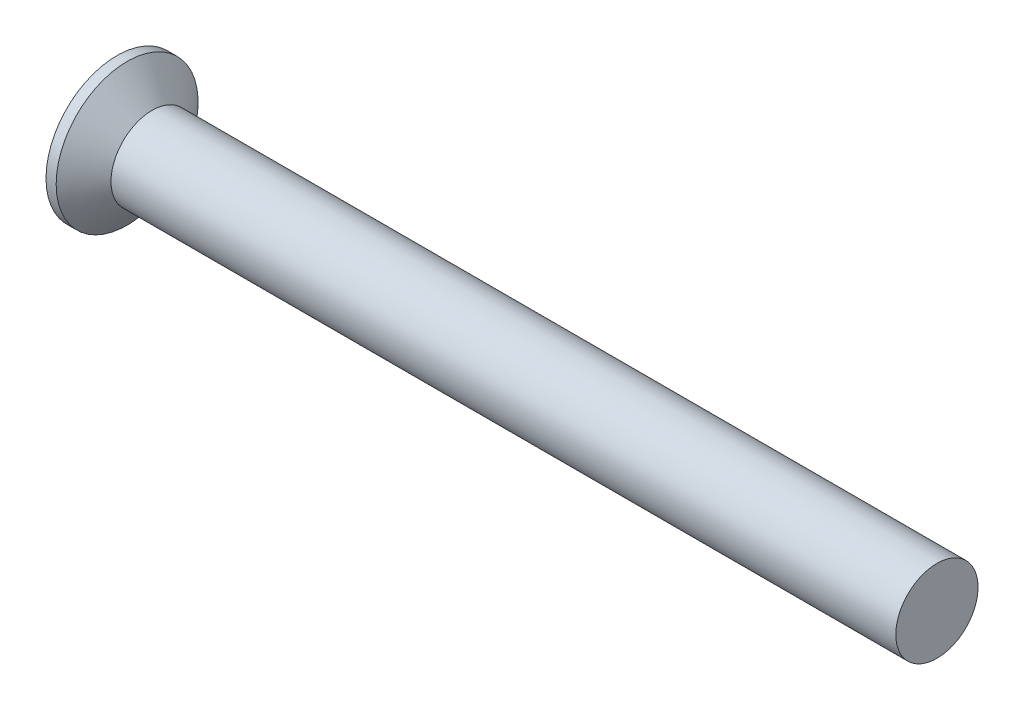
from build123d import *


with BuildPart() as part:
    # BodySke → Base-Revolve (revolve)
    with BuildSketch(Plane.XY):
        Polygon((0, 0), (0, 3.0226), (0.432943468, 3.0226), (1.4986, 1.7526), (34.925, 1.7526), (34.925, 0), align=None)
    revolve(axis=Axis((-6.35, 0, 0), (1, 0, 0)))


solid = part.part
